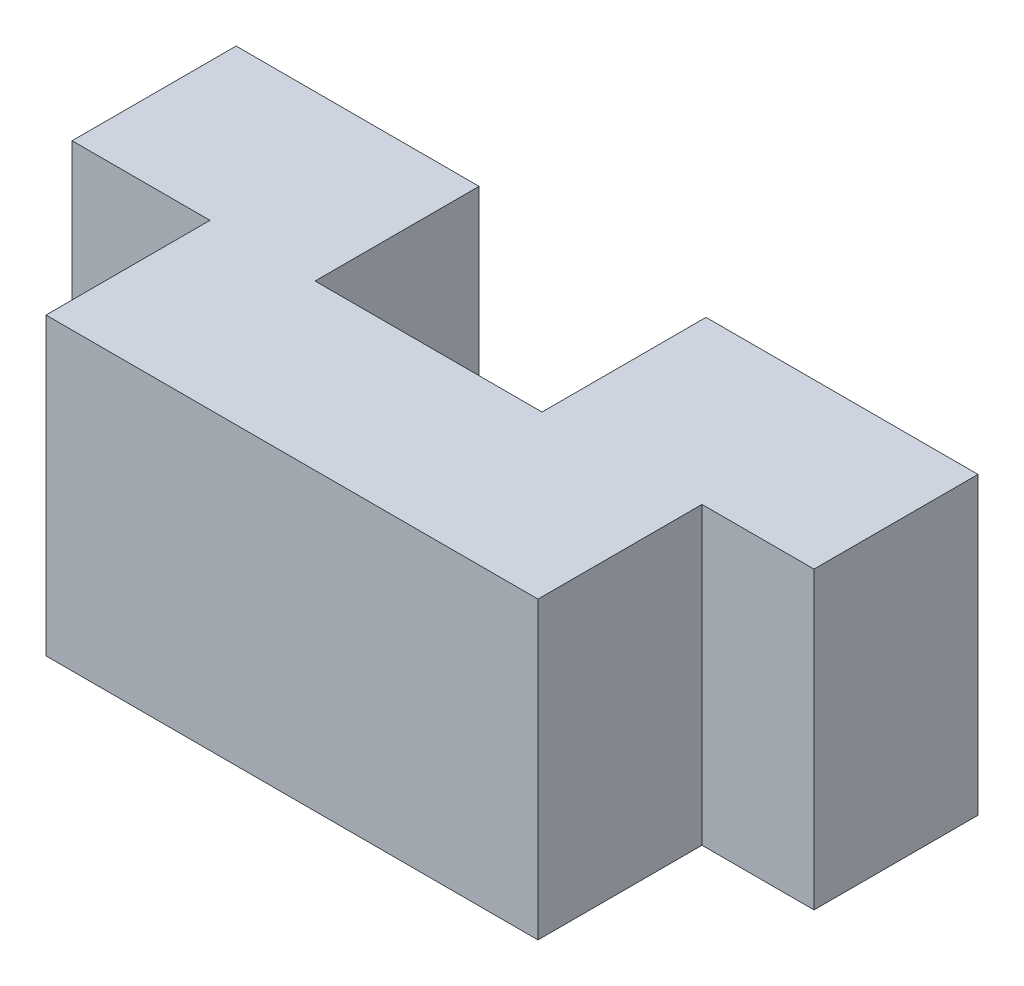
from build123d import *

# Parameters (mm, degrees)
SKETCH1_W           = 15
SKETCH1_H           = 9
BOSS_EXTRUDE1_DEPTH = 5
SKETCH2_W           = 7.408175253
SKETCH2_H           = 9
SKETCH2_W_2         = 8.292733492
BOSS_EXTRUDE2_DEPTH = 5


with BuildPart() as part:
    # Sketch1 → Boss-Extrude1 (new body)
    with BuildSketch(Plane.XY):
        Rectangle(SKETCH1_W, SKETCH1_H)
    extrude(amount=BOSS_EXTRUDE1_DEPTH)

    # Sketch2 → Boss-Extrude2 (add)
    with BuildSketch(Plane.XY):
        with Locations((-8.00051336, 0)):
            Rectangle(SKETCH2_W, SKETCH2_H)
        with Locations((6.768450098, 0)):
            Rectangle(SKETCH2_W_2, SKETCH2_H)
    extrude(amount=-BOSS_EXTRUDE2_DEPTH)


solid = part.part
